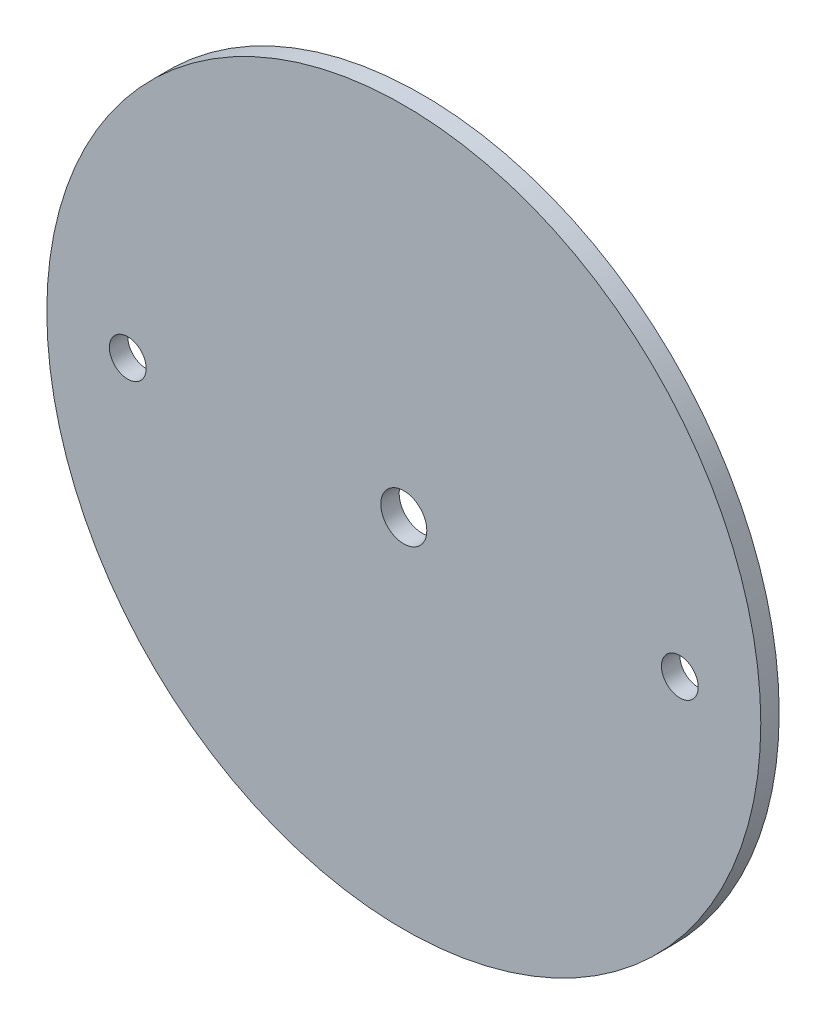
from build123d import *

# Parameters (mm, degrees)
SKETCH1_R                          = 61.595
BOSS_EXTRUDE1_DEPTH                = 1.5875
F_1_4_0_25_DIAMETER_HOLE1_D        = 6.35
F_5_16_0_3125_DIAMETER_HOLE1_D     = 7.9375
F_5_16_0_3125_DIAMETER_HOLE1_DEPTH = 3.302


with BuildPart() as part:
    # Sketch1 → Boss-Extrude1 (new body, symmetric)
    with BuildSketch(Plane.XY):
        Circle(SKETCH1_R)
    extrude(amount=BOSS_EXTRUDE1_DEPTH, both=True)

    # 1/4 (0.25) Diameter Hole1 (through all)
    with Locations(Plane.XY.offset(1.5875)):
        with Locations((-47.625, 0), (47.625, 0)):
            Hole(F_1_4_0_25_DIAMETER_HOLE1_D / 2)

    # 5/16 (0.3125) Diameter Hole1
    with Locations(Plane.XY.offset(1.5875)):
        with Locations((0, 0)):
            Hole(F_5_16_0_3125_DIAMETER_HOLE1_D / 2, depth=F_5_16_0_3125_DIAMETER_HOLE1_DEPTH)


solid = part.part
